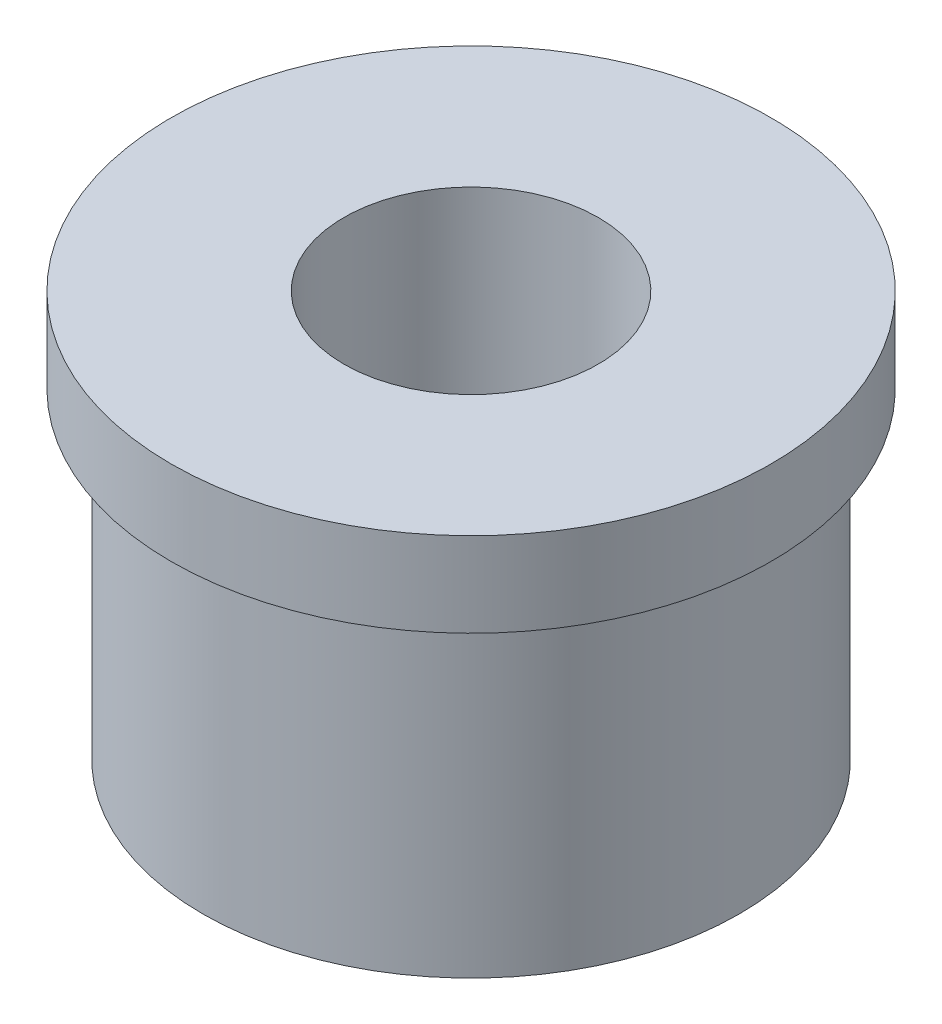
from build123d import *

# Parameters (mm, degrees)
SKETCH1_R           = 6.35
SKETCH1_R_2         = 3.01
BOSS_EXTRUDE1_DEPTH = 9.6
SKETCH2_R           = 7.1
SKETCH2_R_2         = 5
BOSS_EXTRUDE2_DEPTH = 2


with BuildPart() as part:
    # Sketch1 → Boss-Extrude1 (new body)
    with BuildSketch(Plane(origin=(0, 0, 0), x_dir=(1, 0, 0), z_dir=(0, 1, 0))):
        Circle(SKETCH1_R)
        Circle(SKETCH1_R_2, mode=Mode.SUBTRACT)
    extrude(amount=BOSS_EXTRUDE1_DEPTH)

    # Sketch2 → Boss-Extrude2 (add)
    with BuildSketch(Plane(origin=(0, 9.6, 0), x_dir=(-1, 0, 0), z_dir=(0, 1, 0))):
        Circle(SKETCH2_R)
        Circle(SKETCH2_R_2, mode=Mode.SUBTRACT)
    extrude(amount=-BOSS_EXTRUDE2_DEPTH)


solid = part.part
